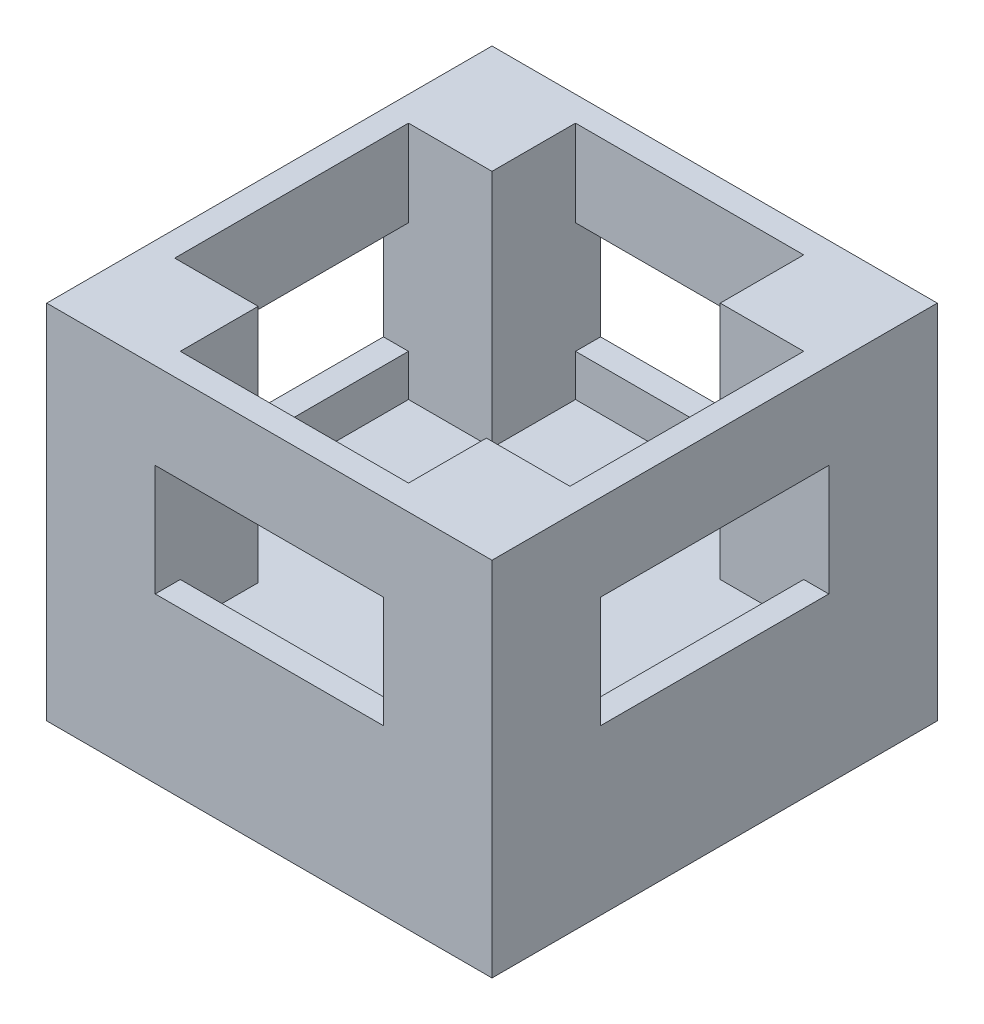
from build123d import *

# Parameters (mm, degrees)
SKETCH1_W           = 10.16
SKETCH1_H           = 10.16
BOSS_EXTRUDE1_DEPTH = 8.255
SKETCH2_W           = 3.556
SKETCH2_H           = 2.54
CUT_EXTRUDE3_DEPTH  = 10.16
CUT_EXTRUDE4_START  = -0.5715
SKETCH4_W           = 5.207
SKETCH4_H           = 5.461
CUT_EXTRUDE4_DEPTH  = 9.017
CUT_EXTRUDE5_START  = -0.5715
SKETCH5_W           = 5.334
SKETCH5_H           = 5.461
CUT_EXTRUDE5_DEPTH  = 9.017
SKETCH6_W           = 3.556
SKETCH6_H           = 2.54
CUT_EXTRUDE6_DEPTH  = 10.16
SKETCH7_W           = 5.207
SKETCH7_H           = 2.54
CUT_EXTRUDE7_DEPTH  = 10.16
SKETCH8_W           = 5.207
SKETCH8_H           = 2.54
CUT_EXTRUDE8_DEPTH  = 10.16


with BuildPart() as part:
    # Sketch1 → Boss-Extrude1 (new body)
    with BuildSketch(Plane(origin=(0, 0, 0), x_dir=(1, 0, 0), z_dir=(0, 1, 0))):
        with Locations((5.08, 5.08)):
            Rectangle(SKETCH1_W, SKETCH1_H)
    extrude(amount=BOSS_EXTRUDE1_DEPTH)

    # Sketch2 → Cut-Extrude3 (cut)
    with BuildSketch(Plane.XY):
        with Locations((5.08, 5.0165)):
            Rectangle(SKETCH2_W, SKETCH2_H)
    extrude(amount=-CUT_EXTRUDE3_DEPTH, mode=Mode.SUBTRACT)

    # Sketch4 → Cut-Extrude4 (cut)
    with BuildSketch(Plane.XY.offset(CUT_EXTRUDE4_START)):
        with Locations((5.08, 5.5245)):
            Rectangle(SKETCH4_W, SKETCH4_H)
    extrude(amount=-CUT_EXTRUDE4_DEPTH, mode=Mode.SUBTRACT)

    # Sketch5 → Cut-Extrude5 (cut)
    with BuildSketch(Plane(origin=(10.16, 0, 0), x_dir=(0, 0, -1), z_dir=(1, 0, 0)).offset(CUT_EXTRUDE5_START)):
        with Locations((5.0165, 5.5245)):
            Rectangle(SKETCH5_W, SKETCH5_H)
    extrude(amount=-CUT_EXTRUDE5_DEPTH, mode=Mode.SUBTRACT)

    # Sketch6 → Cut-Extrude6 (cut)
    with BuildSketch(Plane(origin=(10.16, 0, 0), x_dir=(0, 0, -1), z_dir=(1, 0, 0))):
        with Locations((5.08, 5.0165)):
            Rectangle(SKETCH6_W, SKETCH6_H)
    extrude(amount=-CUT_EXTRUDE6_DEPTH, mode=Mode.SUBTRACT)

    # Sketch7 → Cut-Extrude7 (cut)
    with BuildSketch(Plane.XY):
        with Locations((5.08, 5.0165)):
            Rectangle(SKETCH7_W, SKETCH7_H)
    extrude(amount=-CUT_EXTRUDE7_DEPTH, mode=Mode.SUBTRACT)

    # Sketch8 → Cut-Extrude8 (cut)
    with BuildSketch(Plane(origin=(10.16, 0, 0), x_dir=(0, 0, -1), z_dir=(1, 0, 0))):
        with Locations((5.08, 5.0165)):
            Rectangle(SKETCH8_W, SKETCH8_H)
    extrude(amount=-CUT_EXTRUDE8_DEPTH, mode=Mode.SUBTRACT)


solid = part.part
